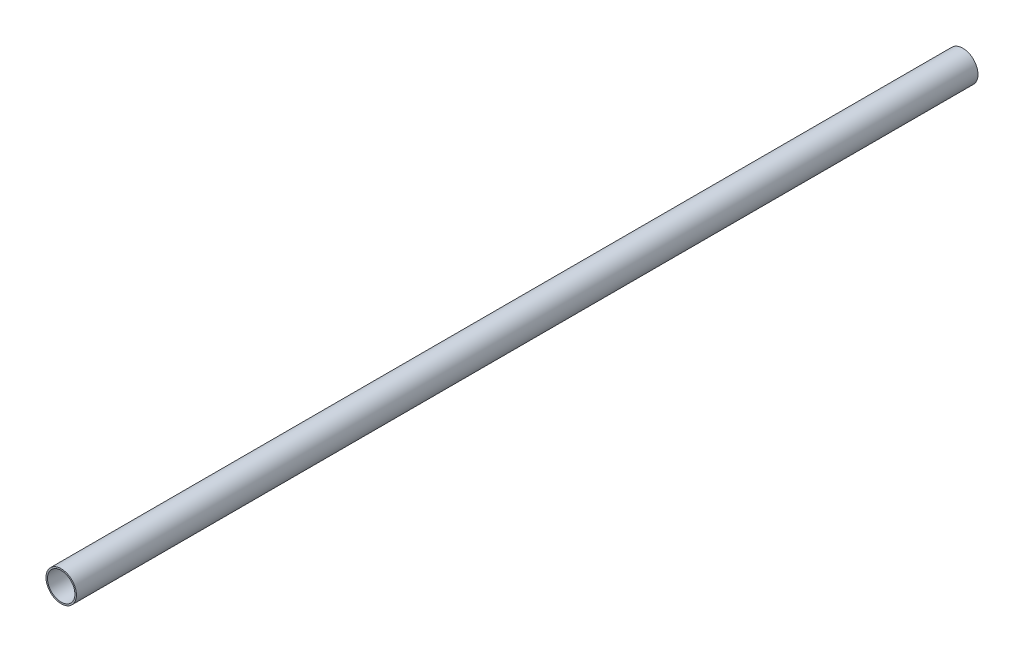
from build123d import *

# Parameters (mm, degrees)
SKETCH1_R           = 12.7
SKETCH1_R_2         = 11.4554
BOSS_EXTRUDE1_DEPTH = 752.856


with BuildPart() as part:
    # Sketch1 → Boss-Extrude1 (new body)
    with BuildSketch(Plane.XY):
        Circle(SKETCH1_R)
        Circle(SKETCH1_R_2, mode=Mode.SUBTRACT)
    extrude(amount=BOSS_EXTRUDE1_DEPTH)


solid = part.part
